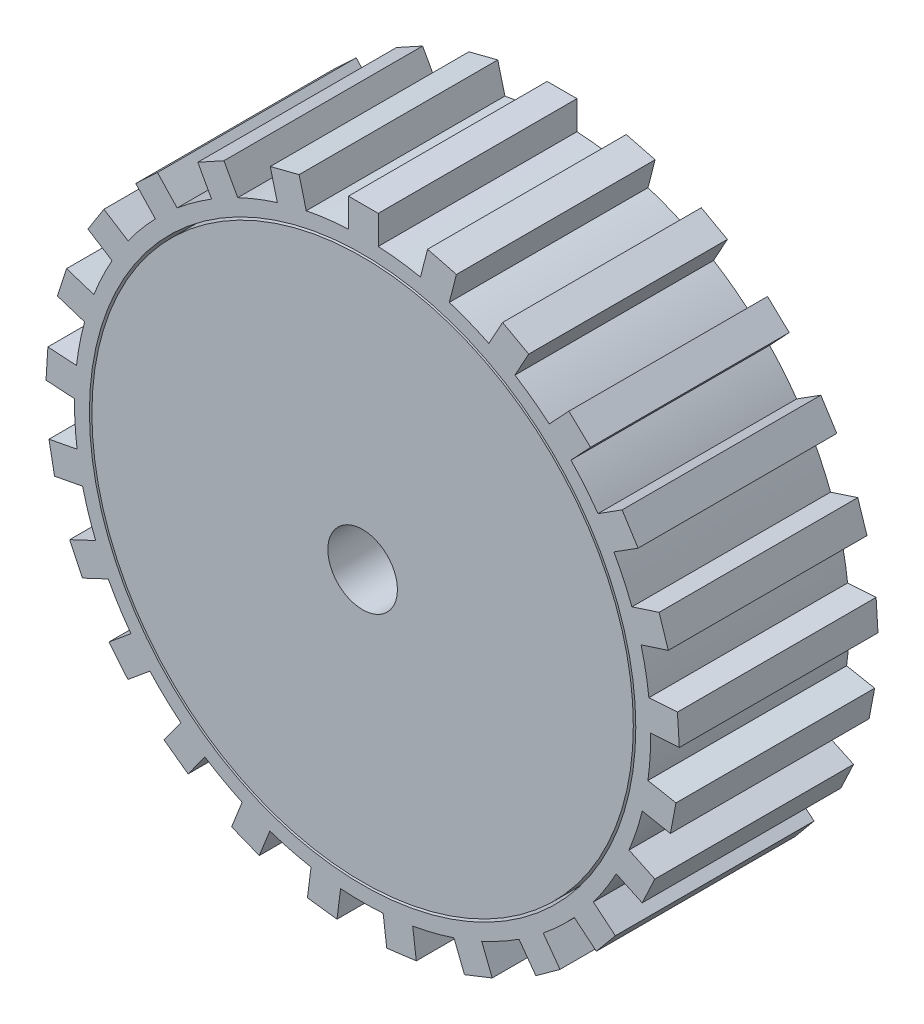
from build123d import *

# Parameters (mm, degrees)
SKETCH1_R           = 27.5
BOSS_EXTRUDE2_DEPTH = 20
SKETCH2_R           = 27.249999983
BOSS_EXTRUDE5_DEPTH = 20
SKETCH3_R           = 3.5
CUT_EXTRUDE3_DEPTH  = 21


with BuildPart() as part:
    # Sketch1 → Boss-Extrude2 (new body)
    with BuildSketch(Plane.XY):
        with BuildLine():
            Line((-1.424336069, 28.965000721), (-1.424336069, 31.841424695))
            Line((-1.424336069, 31.841424695), (1.575663931, 31.841424695))
            Line((1.575663931, 31.841424695), (1.575663931, 28.957162899))
            ThreePointArc((1.575663931, 28.957162899), (3.709819287, 28.76173223), (5.823714829, 28.409229937))
            Line((5.823714829, 28.409229937), (6.539052383, 31.195285762))
            Line((6.539052383, 31.195285762), (9.444801866, 30.449216101))
            Line((9.444801866, 30.449216101), (8.727515125, 27.655568693))
            ThreePointArc((8.727515125, 27.655568693), (10.746020435, 26.935534983), (12.705840306, 26.068402754))
            Line((12.705840306, 26.068402754), (14.091568124, 28.589032297))
            Line((14.091568124, 28.589032297), (16.720488164, 27.143771275))
            Line((16.720488164, 27.143771275), (15.330984447, 24.616273396))
            ThreePointArc((15.330984447, 24.616273396), (17.107009598, 23.416879011), (18.789611108, 22.089601953))
            Line((18.789611108, 22.089601953), (20.758658815, 24.186424789))
            Line((20.758658815, 24.186424789), (22.945564697, 22.132783471))
            Line((22.945564697, 22.132783471), (20.971151632, 20.030247109))
            ThreePointArc((20.971151632, 20.030247109), (22.393102433, 18.42685441), (23.69276154, 16.722830221))
            Line((23.69276154, 16.722830221), (26.121406627, 18.26409526))
            Line((26.121406627, 18.26409526), (27.728887012, 15.731111484))
            Line((27.728887012, 15.731111484), (25.293624233, 14.18564673))
            ThreePointArc((25.293624233, 14.18564673), (26.272154286, 12.279002776), (27.107208629, 10.305301565))
            Line((27.107208629, 10.305301565), (29.842850394, 11.194165456))
            Line((29.842850394, 11.194165456), (30.769901377, 8.340995907))
            Line((30.769901377, 8.340995907), (28.026805401, 7.449709996))
            ThreePointArc((28.026805401, 7.449709996), (28.500430063, 5.35961624), (28.818410107, 3.24025291))
            Line((28.818410107, 3.24025291), (31.689158115, 3.420865066))
            Line((31.689158115, 3.420865066), (31.877529674, 0.426784881))
            Line((31.877529674, 0.426784881), (28.99895931, 0.245680584))
            ThreePointArc((28.99895931, 0.245680584), (28.937919002, -1.896534697), (28.718844891, -4.028392751))
            Line((28.718844891, -4.028392751), (31.544319488, -4.567380856))
            Line((31.544319488, -4.567380856), (30.982175544, -7.514242609))
            Line((30.982175544, -7.514242609), (28.149001955, -6.973785842))
            ThreePointArc((28.149001955, -6.973785842), (27.557132063, -9.033519383), (26.814769029, -11.04391968))
            Line((26.814769029, -11.04391968), (29.417435256, -12.268641442))
            Line((29.417435256, -12.268641442), (28.140097381, -14.9831226))
            Line((28.140097381, -14.9831226), (25.530339282, -13.755063655))
            ThreePointArc((25.530339282, -13.755063655), (24.44482917, -15.602894824), (23.225822612, -17.365516519))
            Line((23.225822612, -17.365516519), (25.442145376, -19.199018165))
            Line((25.442145376, -19.199018165), (23.529873407, -21.510557894))
            Line((23.529873407, -21.510557894), (21.307511498, -19.672060232))
            ThreePointArc((21.307511498, -19.672060232), (19.796567757, -21.191882999), (18.177512342, -22.59597409))
            Line((18.177512342, -22.59597409), (19.868231933, -24.923049968))
            Line((19.868231933, -24.923049968), (17.44118095, -26.686405725))
            Line((17.44118095, -26.686405725), (15.745854403, -24.352988916))
            ThreePointArc((15.745854403, -24.352988916), (13.904415186, -25.449307227), (11.987042119, -26.406643506))
            Line((11.987042119, -26.406643506), (13.045924408, -29.081074881))
            Line((13.045924408, -29.081074881), (10.25659495, -30.185448539))
            Line((10.25659495, -30.185448539), (9.194827367, -27.503729742))
            ThreePointArc((9.194827367, -27.503729742), (7.138597072, -28.107657886), (5.043381954, -28.558086394))
            Line((5.043381954, -28.558086394), (5.403893472, -31.411828906))
            Line((5.403893472, -31.411828906), (2.427549368, -31.787828607))
            Line((2.427549368, -31.787828607), (2.066055511, -28.926310076))
            ThreePointArc((2.066055511, -28.926310076), (-0.07576535, -28.999901028), (-2.217172447, -28.915119684))
            Line((-2.217172447, -28.915119684), (-2.577683965, -31.768862196))
            Line((-2.577683965, -31.768862196), (-5.554028069, -31.392862496))
            Line((-5.554028069, -31.392862496), (-5.192534211, -28.531343965))
            ThreePointArc((-5.192534211, -28.531343965), (-7.285367157, -28.069973733), (-9.338413749, -27.455309662))
            Line((-9.338413749, -27.455309662), (-10.397296038, -30.129741037))
            Line((-10.397296038, -30.129741037), (-13.186625496, -29.025367379))
            Line((-13.186625496, -29.025367379), (-12.124857912, -26.343648582))
            ThreePointArc((-12.124857912, -26.343648582), (-14.037202551, -25.376306755), (-15.872888171, -24.270381561))
            Line((-15.872888171, -24.270381561), (-17.563607762, -26.597457439))
            Line((-17.563607762, -26.597457439), (-19.990658746, -24.834101682))
            Line((-19.990658746, -24.834101682), (-18.295332198, -22.500684873))
            ThreePointArc((-18.295332198, -22.500684873), (-19.907028884, -21.088153096), (-21.410010653, -19.560456126))
            Line((-21.410010653, -19.560456126), (-23.626333417, -21.393957772))
            Line((-23.626333417, -21.393957772), (-25.538605386, -19.082418044))
            Line((-25.538605386, -19.082418044), (-23.316243477, -17.243920382))
            ThreePointArc((-23.316243477, -17.243920382), (-24.526023379, -15.474953221), (-25.601863425, -13.621475294))
            Line((-25.601863425, -13.621475294), (-28.204529651, -14.846197056))
            Line((-28.204529651, -14.846197056), (-29.481867526, -12.131715899))
            Line((-29.481867526, -12.131715899), (-26.872109426, -10.903656955))
            ThreePointArc((-26.872109426, -10.903656955), (-27.603957625, -8.889405122), (-28.185056961, -6.826607073))
            Line((-28.185056961, -6.826607073), (-31.010531558, -7.365595179))
            Line((-31.010531558, -7.365595179), (-31.572675502, -4.418733427))
            Line((-31.572675502, -4.418733427), (-28.739501912, -3.87827666))
            ThreePointArc((-28.739501912, -3.87827666), (-28.947433693, -1.745303007), (-28.99727971, 0.397201976))
            Line((-28.99727971, 0.397201976), (-31.868027719, 0.577814132))
            Line((-31.868027719, 0.577814132), (-31.67965616, 3.571894317))
            Line((-31.67965616, 3.571894317), (-28.801085796, 3.390790021))
            ThreePointArc((-28.801085796, 3.390790021), (-28.472036041, 5.508462915), (-27.987496731, 7.596053365))
            Line((-27.987496731, 7.596053365), (-30.723138496, 8.484917256))
            Line((-30.723138496, 8.484917256), (-29.796087512, 11.338086805))
            Line((-29.796087512, 11.338086805), (-27.052991537, 10.446800894))
            ThreePointArc((-27.052991537, 10.446800894), (-26.207635651, 12.416111854), (-25.219156402, 14.317616785))
            Line((-25.219156402, 14.317616785), (-27.647801489, 15.858881824))
            Line((-27.647801489, 15.858881824), (-26.040321104, 18.3918656))
            Line((-26.040321104, 18.3918656), (-23.605058325, 16.846400846))
            ThreePointArc((-23.605058325, 16.846400846), (-22.296513129, 18.543610821), (-20.866203726, 20.139551685))
            Line((-20.866203726, 20.139551685), (-22.835251433, 22.236374521))
            Line((-22.835251433, 22.236374521), (-20.648345551, 24.290015839))
            Line((-20.648345551, 24.290015839), (-18.673932486, 22.187479477))
            ThreePointArc((-18.673932486, 22.187479477), (-16.984418686, 23.505946522), (-15.20215073, 24.696044485))
            Line((-15.20215073, 24.696044485), (-16.587878547, 27.216674028))
            Line((-16.587878547, 27.216674028), (-13.958958507, 28.661935051))
            Line((-13.958958507, 28.661935051), (-12.56945479, 26.134437172))
            ThreePointArc((-12.56945479, 26.134437172), (-10.605130752, 26.991317154), (-8.582890693, 27.700793984))
            Line((-8.582890693, 27.700793984), (-9.298228247, 30.48684981))
            Line((-9.298228247, 30.48684981), (-6.392478763, 31.232919471))
            Line((-6.392478763, 31.232919471), (-5.675192023, 28.439272064))
            ThreePointArc((-5.675192023, 28.439272064), (-3.559483451, 28.780724063), (-1.424336069, 28.965000721))
        make_face()
        Circle(SKETCH1_R, mode=Mode.SUBTRACT)
    extrude(amount=BOSS_EXTRUDE2_DEPTH)


with BuildPart() as body_2:
    # Sketch2 → Boss-Extrude5 (new body)
    with BuildSketch(Plane.XY.offset(20)):
        Circle(SKETCH2_R)
    extrude(amount=-BOSS_EXTRUDE5_DEPTH)

    # Sketch3 → Cut-Extrude3 (cut, through all)
    with BuildSketch(Plane(origin=(0, 0, 0), x_dir=(-1, 0, 0), z_dir=(0, 0, -1))):
        Circle(SKETCH3_R)
    extrude(amount=-CUT_EXTRUDE3_DEPTH, mode=Mode.SUBTRACT)


solid = Compound([part.part, body_2.part])
